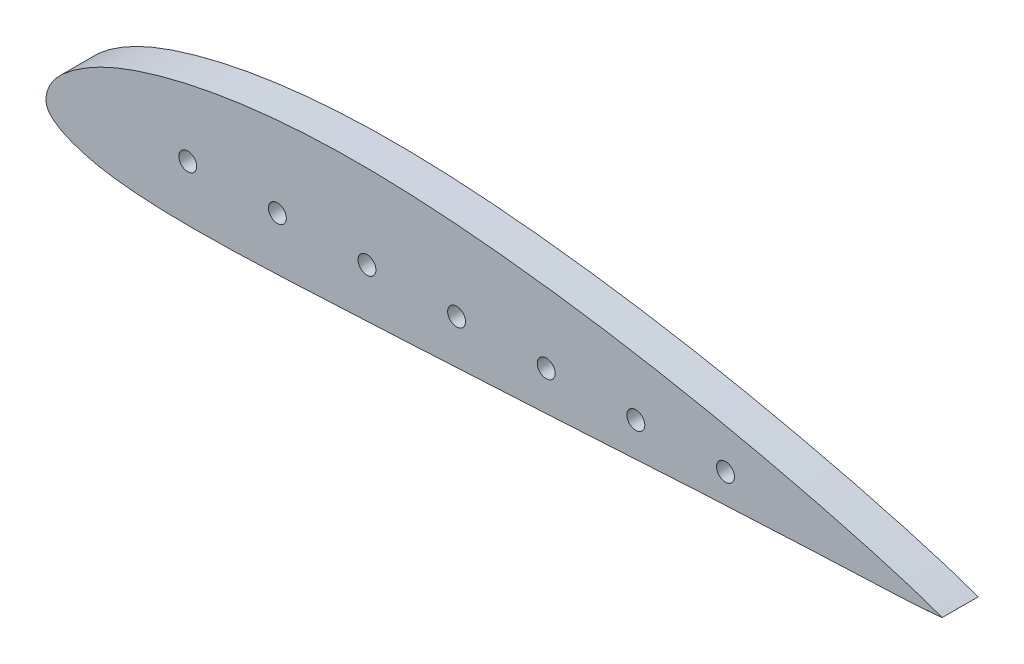
from build123d import *

# Parameters (mm, degrees)
BOSS_EXTRUDE1_DEPTH = 5.08
CUT_EXTRUDE1_REACH  = 7.08
SKETCH3_R           = 1.27


with BuildPart() as part:
    # Sketch1 → Boss-Extrude1 (new body)
    with BuildSketch(Plane.XY):
        with BuildLine():
            add(Edge.make_bspline(
                [(109.451798245, -5.08), (109.454459179, -5.069425808), (109.156485113, -4.988933703), (108.862479979, -4.854611957), (108.123918832, -4.601174607), (107.210252378, -4.275113763), (105.996957401, -3.864128041), (104.539237084, -3.396389688), (102.825319981, -2.872694168), (100.868609031, -2.304294985), (98.677120018, -1.688692503), (96.260769688, -1.030225668), (93.628788556, -0.338112688), (90.79222133, 0.379443626), (87.763546501, 1.114318743), (84.55642271, 1.862295436), (81.18393025, 2.616999363), (77.660462663, 3.370535669), (74.001087147, 4.112971199), (70.221434176, 4.832935171), (66.338384706, 5.526147732), (62.367760923, 6.181640202), (58.32651251, 6.794671047), (54.232265427, 7.358114275), (50.102257175, 7.865217019), (45.955204492, 8.314460057), (41.807883769, 8.694582393), (37.677836385, 8.999359849), (33.583119049, 9.219581812), (29.540935954, 9.344844034), (25.569148845, 9.366151666), (21.684289856, 9.28357116), (17.90296947, 9.090805086), (14.241437004, 8.790106625), (10.715843335, 8.386537728), (7.34129415, 7.887908031), (4.131540875, 7.302313473), (1.101321001, 6.629486178), (-1.737529564, 5.885321391), (-4.374224197, 5.081382029), (-6.798034097, 4.215123829), (-8.99434944, 3.276584408), (-10.955144335, 2.280631456), (-12.668635429, 1.246216085), (-14.139910443, 0.212705201), (-15.357677489, -0.820744476), (-16.329587539, -1.85673894), (-17.020262836, -2.922810358), (-17.433311549, -3.968099245), (-17.594054464, -4.936103088), (-17.470217518, -5.808875047), (-17.008669931, -6.541051293), (-16.289135391, -7.160460761), (-15.334664795, -7.755073977), (-14.115913472, -8.304202011), (-12.650913051, -8.825097951), (-10.933605398, -9.28593559), (-8.971727491, -9.660437727), (-6.776564623, -9.951959321), (-4.357404481, -10.168668041), (-1.723420738, -10.310129126), (1.11440167, -10.382650245), (4.143511528, -10.392587524), (7.351017748, -10.353447041), (10.723916806, -10.264224791), (14.24763074, -10.129211039), (17.907156532, -9.963698745), (21.686445322, -9.777901033), (25.569576829, -9.583170836), (29.540051238, -9.384394628), (33.581240653, -9.18046487), (37.675363567, -8.970453501), (41.805001468, -8.752323033), (45.952009418, -8.526789328), (50.098989658, -8.293522134), (54.228512616, -8.053073247), (58.322553669, -7.811052079), (62.363523048, -7.567748949), (66.333787226, -7.330550972), (70.217091812, -7.108099854), (73.996496557, -6.896309381), (77.656293687, -6.702849791), (81.180169582, -6.524192177), (84.552908569, -6.359431078), (87.760133831, -6.207663839), (90.788632993, -6.066464496), (93.625397987, -5.938389564), (96.25771185, -5.823142898), (98.674461054, -5.719648395), (100.865946842, -5.631528219), (102.821934838, -5.547728652), (104.536131886, -5.464713443), (105.99420693, -5.377255547), (107.208082176, -5.287914508), (108.124802465, -5.203984211), (108.857579465, -5.146531285), (109.16405856, -5.095860832), (109.449285024, -5.089987204), (109.451798245, -5.08)],
                knots=[0, 0, 0, 0, 0.000551748, 0.002206993, 0.004953318, 0.008768597, 0.01362371, 0.019491754, 0.026331376, 0.034118238, 0.042814764, 0.052380389, 0.062780118, 0.073959334, 0.085864938, 0.098446304, 0.111647061, 0.125414729, 0.139681019, 0.154378272, 0.169446878, 0.184821178, 0.200432901, 0.21622378, 0.232116859, 0.248051216, 0.263959621, 0.279776549, 0.295442409, 0.310884918, 0.326054012, 0.340892172, 0.355348528, 0.369377925, 0.382929883, 0.395952713, 0.408409585, 0.420261405, 0.431467241, 0.441987752, 0.451798802, 0.46090969, 0.469303541, 0.476945896, 0.483797691, 0.489858128, 0.495197566, 0.499996833, 0.504303705, 0.507974056, 0.511122506, 0.514149356, 0.517650444, 0.521912415, 0.526982255, 0.532915788, 0.539692296, 0.547308645, 0.555757426, 0.565025083, 0.575098193, 0.585939785, 0.597509159, 0.609762381, 0.622648894, 0.636121865, 0.650117759, 0.664572179, 0.679425296, 0.69461325, 0.710068303, 0.725732643, 0.741529127, 0.757394896, 0.773262272, 0.789063315, 0.80473434, 0.820197409, 0.835393048, 0.850252142, 0.864711864, 0.878713432, 0.892194297, 0.90509186, 0.917358005, 0.928939748, 0.939788483, 0.949855831, 0.959093409, 0.967472192, 0.974954677, 0.981503133, 0.987099409, 0.991709921, 0.995322896, 0.997916482, 0.99947888, 1, 1, 1, 1], degree=3))
        make_face()
    extrude(amount=BOSS_EXTRUDE1_DEPTH)

    # Sketch3 → Cut-Extrude1 (cut, up to next)
    with BuildSketch(Plane.XY.offset(5.08), mode=Mode.PRIVATE) as cut_extrude1_sk1:
        with Locations((2.54, -2.54)):
            Circle(SKETCH3_R)
    cut_extrude1_tool1 = extrude(cut_extrude1_sk1.sketch, amount=-CUT_EXTRUDE1_REACH, mode=Mode.PRIVATE) & part.part
    add(cut_extrude1_tool1.solids().sort_by_distance((2.54, -2.54, 5.08))[0], mode=Mode.SUBTRACT)
    # Sketch3 → Cut-Extrude1 (cut, up to next)
    with BuildSketch(Plane.XY.offset(5.08), mode=Mode.PRIVATE) as cut_extrude1_sk2:
        with Locations((15.24, -2.54)):
            Circle(SKETCH3_R)
    cut_extrude1_tool2 = extrude(cut_extrude1_sk2.sketch, amount=-CUT_EXTRUDE1_REACH, mode=Mode.PRIVATE) & part.part
    add(cut_extrude1_tool2.solids().sort_by_distance((15.24, -2.54, 5.08))[0], mode=Mode.SUBTRACT)
    # Sketch3 → Cut-Extrude1 (cut, up to next)
    with BuildSketch(Plane.XY.offset(5.08), mode=Mode.PRIVATE) as cut_extrude1_sk3:
        with Locations((27.94, -2.54)):
            Circle(SKETCH3_R)
    cut_extrude1_tool3 = extrude(cut_extrude1_sk3.sketch, amount=-CUT_EXTRUDE1_REACH, mode=Mode.PRIVATE) & part.part
    add(cut_extrude1_tool3.solids().sort_by_distance((27.94, -2.54, 5.08))[0], mode=Mode.SUBTRACT)
    # Sketch3 → Cut-Extrude1 (cut, up to next)
    with BuildSketch(Plane.XY.offset(5.08), mode=Mode.PRIVATE) as cut_extrude1_sk4:
        with Locations((53.34, -2.54)):
            Circle(SKETCH3_R)
    cut_extrude1_tool4 = extrude(cut_extrude1_sk4.sketch, amount=-CUT_EXTRUDE1_REACH, mode=Mode.PRIVATE) & part.part
    add(cut_extrude1_tool4.solids().sort_by_distance((53.34, -2.54, 5.08))[0], mode=Mode.SUBTRACT)
    # Sketch3 → Cut-Extrude1 (cut, up to next)
    with BuildSketch(Plane.XY.offset(5.08), mode=Mode.PRIVATE) as cut_extrude1_sk5:
        with Locations((78.74, -2.54)):
            Circle(SKETCH3_R)
    cut_extrude1_tool5 = extrude(cut_extrude1_sk5.sketch, amount=-CUT_EXTRUDE1_REACH, mode=Mode.PRIVATE) & part.part
    add(cut_extrude1_tool5.solids().sort_by_distance((78.74, -2.54, 5.08))[0], mode=Mode.SUBTRACT)
    # Sketch3 → Cut-Extrude1 (cut, up to next)
    with BuildSketch(Plane.XY.offset(5.08), mode=Mode.PRIVATE) as cut_extrude1_sk6:
        with Locations((40.64, -2.54)):
            Circle(SKETCH3_R)
    cut_extrude1_tool6 = extrude(cut_extrude1_sk6.sketch, amount=-CUT_EXTRUDE1_REACH, mode=Mode.PRIVATE) & part.part
    add(cut_extrude1_tool6.solids().sort_by_distance((40.64, -2.54, 5.08))[0], mode=Mode.SUBTRACT)
    # Sketch3 → Cut-Extrude1 (cut, up to next)
    with BuildSketch(Plane.XY.offset(5.08), mode=Mode.PRIVATE) as cut_extrude1_sk7:
        with Locations((66.04, -2.54)):
            Circle(SKETCH3_R)
    cut_extrude1_tool7 = extrude(cut_extrude1_sk7.sketch, amount=-CUT_EXTRUDE1_REACH, mode=Mode.PRIVATE) & part.part
    add(cut_extrude1_tool7.solids().sort_by_distance((66.04, -2.54, 5.08))[0], mode=Mode.SUBTRACT)


solid = part.part
